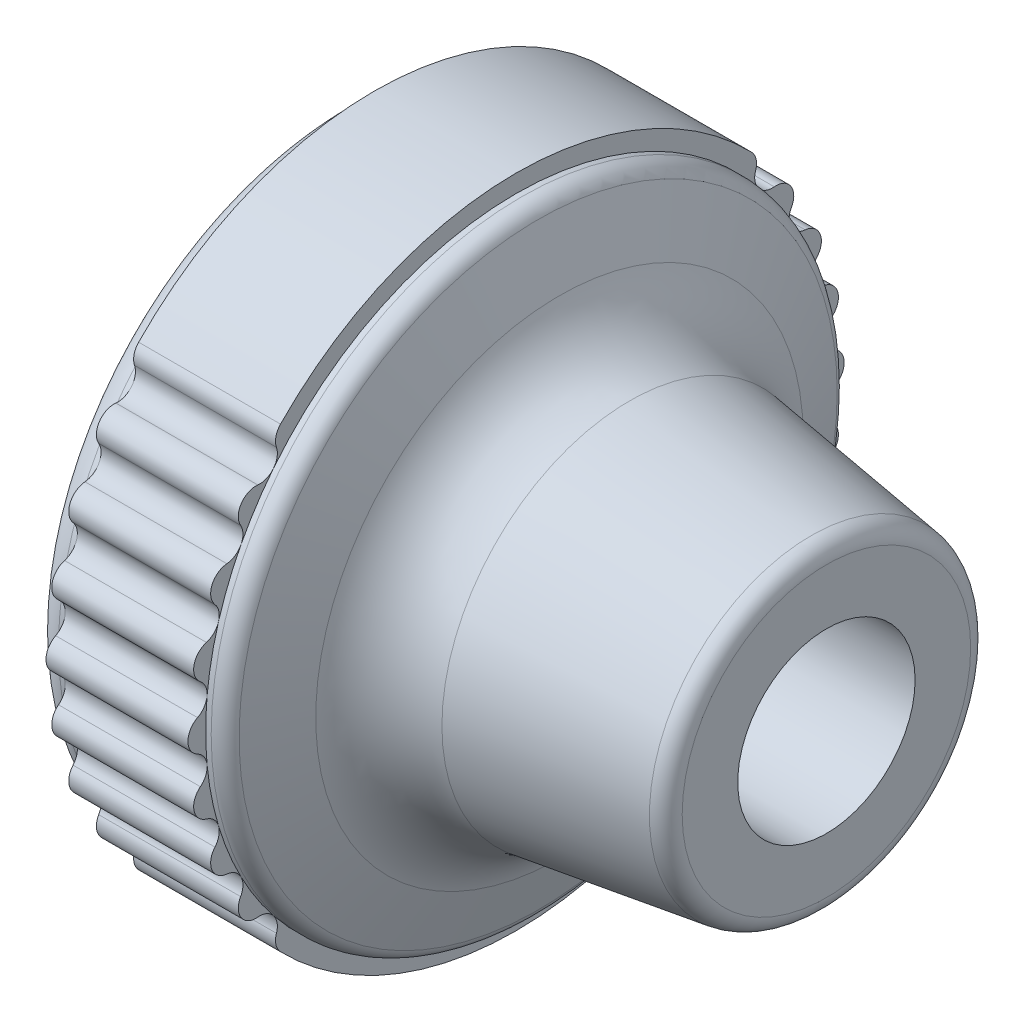
from build123d import *

# Parameters (mm, degrees)
PER_AGE1_D              = 10
PER_AGE1_DEPTH          = 20.5
PER_AGE1_TIP            = 3.004303095
ESQUISSE4_OUTSIDE_W     = 51.064
ESQUISSE4_OUTSIDE_H     = 51.064
ENL_V_MAT_EXTRU_2_DEPTH = 13.500004827


with BuildPart() as part:
    # Esquisse1 → Base-Révolution (revolve)
    with BuildSketch(Plane.XY, mode=Mode.PRIVATE) as base_r_volution_sk:
        with BuildLine():
            Line((0, 17.5), (0, 18.5))
            Line((0, 18.5), (8, 18.5))
            Line((8, 18.5), (8, 17.5))
            Line((8, 17.5), (8.313200902, 17.5))
            ThreePointArc((8.313200902, 17.5), (8.879337334, 17.324311555), (9.246546508, 16.858979079))
            Line((9.246546508, 16.858979079), (10.446259113, 13.739726306))
            ThreePointArc((10.446259113, 13.739726306), (11.997253194, 11.624097191), (14.405880363, 10.584874234))
            Line((14.405880363, 10.584874234), (24.641421356, 9.122654092))
            ThreePointArc((24.641421356, 9.122654092), (25.255453955, 8.78790634), (25.5, 8.132704598))
            Line((25.5, 8.132704598), (25.5, 0))
            Line((25.5, 0), (-4.5, 0))
            ThreePointArc((-4.5, 0), (-3.799049548, 8.364652706), (-1.708679537, 16.494172966))
            ThreePointArc((-1.708679537, 16.494172966), (-1.160964211, 17.222959412), (-0.292419293, 17.5))
            Line((-0.292419293, 17.5), (0, 17.5))
        make_face()
    revolve(base_r_volution_sk.sketch.rotate(Axis((95.260513245, 0, 0), (-1, 0, 0)), 90), axis=Axis((95.260513245, 0, 0), (-1, 0, 0)))  # turned: the seam where the file's is

    # Perçage1
    with Locations(Plane(origin=(25.5, 0, 0), x_dir=(0, 0, -1), z_dir=(1, 0, 0))):
        with Locations((0, 0)):
            Hole(PER_AGE1_D / 2, depth=PER_AGE1_DEPTH)
            with Locations((0, 0, -(PER_AGE1_DEPTH + PER_AGE1_TIP / 2))):  # 118° drill point
                Cone(0, PER_AGE1_D / 2, PER_AGE1_TIP, mode=Mode.SUBTRACT)

    # Esquisse4 outside → Enlèv. mat.-Extru.2 (cut, through all)
    with BuildSketch(Plane(origin=(8, 0, 0), x_dir=(0, 0, -1), z_dir=(1, 0, 0))):
        Rectangle(ESQUISSE4_OUTSIDE_W, ESQUISSE4_OUTSIDE_H)
        with BuildLine():
            ThreePointArc((-17.957142857, 0.889393281), (-18.5, 0), (-17.957142857, -0.889393281))
            ThreePointArc((-17.957142857, -0.889393281), (-17.418918919, -1.682635937), (-17.79535636, -2.564233221))
            ThreePointArc((-17.79535636, -2.564233221), (-18.157937121, -3.541090159), (-17.454878328, -4.310130223))
            ThreePointArc((-17.454878328, -4.310130223), (-16.774965689, -4.985031065), (-16.974612988, -5.922001341))
            ThreePointArc((-16.974612988, -5.922001341), (-17.143103155, -6.954423684), (-16.302302488, -7.576789389))
            ThreePointArc((-16.302302488, -7.576789389), (-15.508197398, -8.108380814), (-15.527199047, -9.063802853))
            ThreePointArc((-15.527199047, -9.063802853), (-15.497610903, -10.103170336), (-14.559029214, -10.55063501))
            ThreePointArc((-14.559029214, -10.55063501), (-13.67429749, -10.920787188), (-13.507953431, -11.865293679))
            ThreePointArc((-13.507953431, -11.865293679), (-13.535960556, -12.405745053), (-13.278297709, -12.881646244))
            ThreePointArc((-13.278297709, -12.881646244), (0, -18.5), (13.278297709, -12.881646244))
            ThreePointArc((13.278297709, -12.881646244), (13.535960556, -12.405745053), (13.507953431, -11.865293679))
            ThreePointArc((13.507953431, -11.865293679), (13.67429749, -10.920787188), (14.559029214, -10.55063501))
            ThreePointArc((14.559029214, -10.55063501), (15.497610903, -10.103170336), (15.527199047, -9.063802853))
            ThreePointArc((15.527199047, -9.063802853), (15.508197398, -8.108380814), (16.302302488, -7.576789389))
            ThreePointArc((16.302302488, -7.576789389), (17.143103155, -6.954423684), (16.974612988, -5.922001341))
            ThreePointArc((16.974612988, -5.922001341), (16.774965689, -4.985031065), (17.454878328, -4.310130223))
            ThreePointArc((17.454878328, -4.310130223), (18.157937121, -3.541090159), (17.79535636, -2.564233221))
            ThreePointArc((17.79535636, -2.564233221), (17.418918919, -1.682635937), (17.957142857, -0.889393281))
            ThreePointArc((17.957142857, -0.889393281), (18.5, 0), (17.957142857, 0.889393281))
            ThreePointArc((17.957142857, 0.889393281), (17.418918919, 1.682635937), (17.79535636, 2.564233221))
            ThreePointArc((17.79535636, 2.564233221), (18.157937121, 3.541090159), (17.454878328, 4.310130223))
            ThreePointArc((17.454878328, 4.310130223), (16.774965689, 4.985031065), (16.974612988, 5.922001341))
            ThreePointArc((16.974612988, 5.922001341), (17.143103155, 6.954423684), (16.302302488, 7.576789389))
            ThreePointArc((16.302302488, 7.576789389), (15.508197398, 8.108380814), (15.527199047, 9.063802853))
            ThreePointArc((15.527199047, 9.063802853), (15.497610903, 10.103170336), (14.559029214, 10.55063501))
            ThreePointArc((14.559029214, 10.55063501), (13.67429749, 10.920787188), (13.507953431, 11.865293679))
            ThreePointArc((13.507953431, 11.865293679), (13.535960556, 12.405745053), (13.278297709, 12.881646244))
            ThreePointArc((13.278297709, 12.881646244), (0, 18.5), (-13.278297709, 12.881646244))
            ThreePointArc((-13.278297709, 12.881646244), (-13.535960556, 12.405745053), (-13.507953431, 11.865293679))
            ThreePointArc((-13.507953431, 11.865293679), (-13.67429749, 10.920787188), (-14.559029214, 10.55063501))
            ThreePointArc((-14.559029214, 10.55063501), (-15.497610903, 10.103170336), (-15.527199047, 9.063802853))
            ThreePointArc((-15.527199047, 9.063802853), (-15.508197398, 8.108380814), (-16.302302488, 7.576789389))
            ThreePointArc((-16.302302488, 7.576789389), (-17.143103155, 6.954423684), (-16.974612988, 5.922001341))
            ThreePointArc((-16.974612988, 5.922001341), (-16.774965689, 4.985031065), (-17.454878328, 4.310130223))
            ThreePointArc((-17.454878328, 4.310130223), (-18.157937121, 3.541090159), (-17.79535636, 2.564233221))
            ThreePointArc((-17.79535636, 2.564233221), (-17.418918919, 1.682635937), (-17.957142857, 0.889393281))
        make_face(mode=Mode.SUBTRACT)
    extrude(amount=-ENL_V_MAT_EXTRU_2_DEPTH, mode=Mode.SUBTRACT)


solid = part.part
